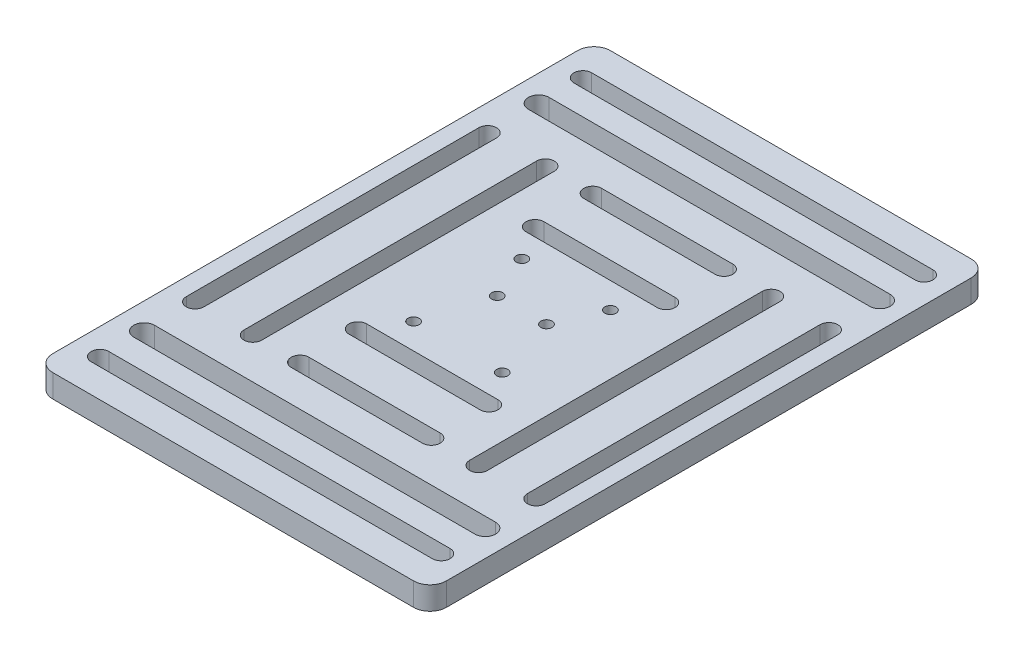
from build123d import *

# Parameters (mm, degrees)
SKETCH_1_W          = 120
SKETCH_1_H          = 170
SKETCH_1_R          = 1.7
EXTRUDE_1_DEPTH     = 7
SKETCH_3_R          = 3.4
CUT_EXTRUDE_1_DEPTH = 3
FILLET_1_R          = 5


with BuildPart() as part:
    # 草图1 → 凸台-拉伸1 (new body)
    with BuildSketch(Plane(origin=(0, 0, 0), x_dir=(1, 0, 0), z_dir=(0, 1, 0))):
        with Locations((4.775862069, 0)):
            Rectangle(SKETCH_1_W, SKETCH_1_H)
        with Locations((-8.724137931, 16.5)):
            Circle(SKETCH_1_R, mode=Mode.SUBTRACT)
        with Locations((18.275862069, 16.5)):
            Circle(SKETCH_1_R, mode=Mode.SUBTRACT)
        with Locations((18.275862069, -16.5)):
            Circle(SKETCH_1_R, mode=Mode.SUBTRACT)
        with Locations((-8.724137931, -16.5)):
            Circle(SKETCH_1_R, mode=Mode.SUBTRACT)
        with Locations((-2.724137931, 3)):
            Circle(SKETCH_1_R, mode=Mode.SUBTRACT)
        with Locations((12.275862069, 3)):
            Circle(SKETCH_1_R, mode=Mode.SUBTRACT)
        with BuildLine():
            Line((-15.224137931, 29.7), (24.775862069, 29.7))
            ThreePointArc((24.775862069, 29.7), (27.475862069, 27), (24.775862069, 24.3))
            Line((24.775862069, 24.3), (-15.224137931, 24.3))
            ThreePointArc((-15.224137931, 24.3), (-17.924137931, 27), (-15.224137931, 29.7))
        make_face(mode=Mode.SUBTRACT)
        with BuildLine():
            Line((-15.224137931, 47.3), (24.775862069, 47.3))
            ThreePointArc((24.775862069, 47.3), (27.475862069, 44.6), (24.775862069, 41.9))
            Line((24.775862069, 41.9), (-15.224137931, 41.9))
            ThreePointArc((-15.224137931, 41.9), (-17.924137931, 44.6), (-15.224137931, 47.3))
        make_face(mode=Mode.SUBTRACT)
        with BuildLine():
            Line((-15.224137931, -29.7), (24.775862069, -29.7))
            ThreePointArc((24.775862069, -29.7), (27.475862069, -27), (24.775862069, -24.3))
            Line((24.775862069, -24.3), (-15.224137931, -24.3))
            ThreePointArc((-15.224137931, -24.3), (-17.924137931, -27), (-15.224137931, -29.7))
        make_face(mode=Mode.SUBTRACT)
        with BuildLine():
            Line((-15.224137931, -47.3), (24.775862069, -47.3))
            ThreePointArc((24.775862069, -47.3), (27.475862069, -44.6), (24.775862069, -41.9))
            Line((24.775862069, -41.9), (-15.224137931, -41.9))
            ThreePointArc((-15.224137931, -41.9), (-17.924137931, -44.6), (-15.224137931, -47.3))
        make_face(mode=Mode.SUBTRACT)
        with BuildLine():
            Line((-44.524137931, 44.6), (-44.524137931, -44.6))
            ThreePointArc((-44.524137931, -44.6), (-47.224137931, -47.3), (-49.924137931, -44.6))
            Line((-49.924137931, -44.6), (-49.924137931, 44.6))
            ThreePointArc((-49.924137931, 44.6), (-47.224137931, 47.3), (-44.524137931, 44.6))
        make_face(mode=Mode.SUBTRACT)
        with BuildLine():
            Line((-26.924137931, 44.6), (-26.924137931, -44.6))
            ThreePointArc((-26.924137931, -44.6), (-29.624137931, -47.3), (-32.324137931, -44.6))
            Line((-32.324137931, -44.6), (-32.324137931, 44.6))
            ThreePointArc((-32.324137931, 44.6), (-29.624137931, 47.3), (-26.924137931, 44.6))
        make_face(mode=Mode.SUBTRACT)
        with BuildLine():
            Line((36.475862069, 44.6), (36.475862069, -44.6))
            ThreePointArc((36.475862069, -44.6), (39.175862069, -47.3), (41.875862069, -44.6))
            Line((41.875862069, -44.6), (41.875862069, 44.6))
            ThreePointArc((41.875862069, 44.6), (39.175862069, 47.3), (36.475862069, 44.6))
        make_face(mode=Mode.SUBTRACT)
        with BuildLine():
            Line((54.075862069, 44.6), (54.075862069, -44.6))
            ThreePointArc((54.075862069, -44.6), (56.775862069, -47.3), (59.475862069, -44.6))
            Line((59.475862069, -44.6), (59.475862069, 44.6))
            ThreePointArc((59.475862069, 44.6), (56.775862069, 47.3), (54.075862069, 44.6))
        make_face(mode=Mode.SUBTRACT)
        with BuildLine():
            Line((56.775862069, 56.997520271), (-47.224137931, 56.997520271))
            ThreePointArc((-47.224137931, 56.997520271), (-50.374920197, 60.148302538), (-47.224137931, 63.299084804))
            Line((-47.224137931, 63.299084804), (56.775862069, 63.299084804))
            ThreePointArc((56.775862069, 63.299084804), (59.926644335, 60.148302538), (56.775862069, 56.997520271))
        make_face(mode=Mode.SUBTRACT)
        with BuildLine():
            Line((56.775862069, 70.890661148), (-47.224137931, 70.890661148))
            ThreePointArc((-47.224137931, 70.890661148), (-49.924137931, 73.590661148), (-47.224137931, 76.290661148))
            Line((-47.224137931, 76.290661148), (56.775862069, 76.290661148))
            ThreePointArc((56.775862069, 76.290661148), (59.475862069, 73.590661148), (56.775862069, 70.890661148))
        make_face(mode=Mode.SUBTRACT)
        with BuildLine():
            Line((56.775862069, -56.997520271), (-47.224137931, -56.997520271))
            ThreePointArc((-47.224137931, -56.997520271), (-50.374920197, -60.148302538), (-47.224137931, -63.299084804))
            Line((-47.224137931, -63.299084804), (56.775862069, -63.299084804))
            ThreePointArc((56.775862069, -63.299084804), (59.926644335, -60.148302538), (56.775862069, -56.997520271))
        make_face(mode=Mode.SUBTRACT)
        with BuildLine():
            Line((56.775862069, -70.890661148), (-47.224137931, -70.890661148))
            ThreePointArc((-47.224137931, -70.890661148), (-49.924137931, -73.590661148), (-47.224137931, -76.290661148))
            Line((-47.224137931, -76.290661148), (56.775862069, -76.290661148))
            ThreePointArc((56.775862069, -76.290661148), (59.475862069, -73.590661148), (56.775862069, -70.890661148))
        make_face(mode=Mode.SUBTRACT)
    extrude(amount=EXTRUDE_1_DEPTH)

    # 草图3 → 切除-拉伸1 (cut)
    with BuildSketch(Plane.XZ):
        with Locations((12.275862069, -3)):
            Circle(SKETCH_3_R)
        with Locations((-2.724137931, -3)):
            Circle(SKETCH_3_R)
        with Locations((18.275862069, 16.5)):
            Circle(SKETCH_3_R)
        with Locations((-8.724137931, 16.5)):
            Circle(SKETCH_3_R)
        with Locations((18.275862069, -16.5)):
            Circle(SKETCH_3_R)
        with Locations((-8.724137931, -16.5)):
            Circle(SKETCH_3_R)
    extrude(amount=-CUT_EXTRUDE_1_DEPTH, mode=Mode.SUBTRACT)

    # 圆角1
    fillet_1_edges = [part.edges().sort_by_distance(p)[0] for p in [
        (-55.224137931, 3.5, -85),
        (64.775862069, 3.5, -85),
        (64.775862069, 3.5, 85),
        (-55.224137931, 3.5, 85),
    ]]
    fillet(fillet_1_edges, radius=FILLET_1_R)


solid = part.part
